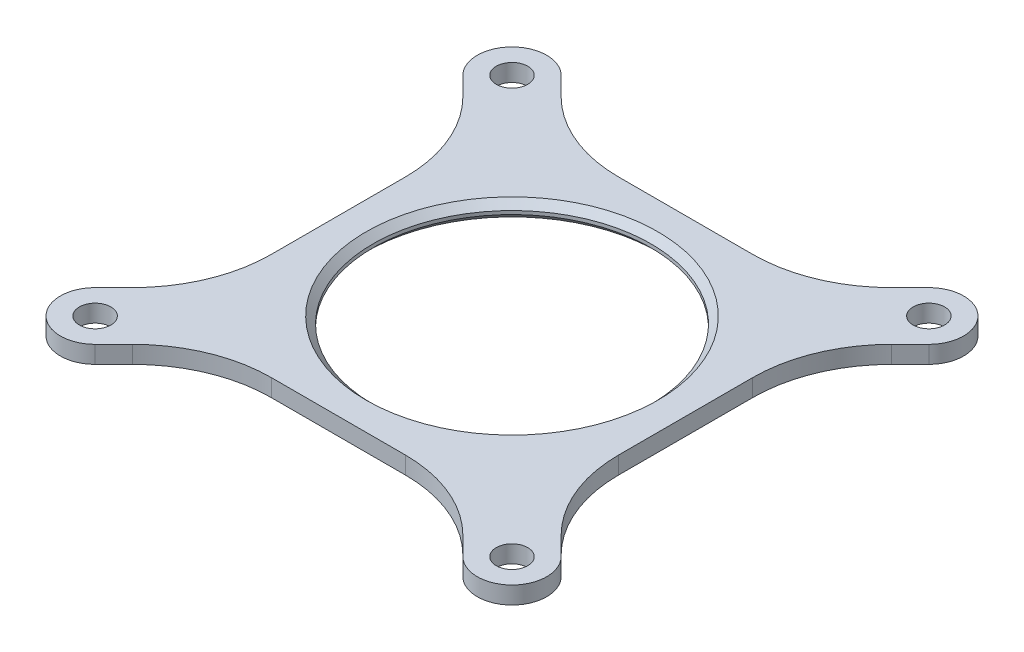
from build123d import *

# Parameters (mm, degrees)
BOSS_EXTRUDE1_DEPTH         = 6.35
SKETCH2_R                   = 50.8
CUT_EXTRUDE1_DEPTH          = 6.35
FILLET1_R                   = 50.8
F_1_2_20_TAPPED_HOLE1_D     = 11.50874
F_1_2_20_TAPPED_HOLE1_DEPTH = 29.21
F_1_2_20_TAPPED_HOLE1_TIP   = 3.45757432
CHAMFER1_SIZE               = 2.54


with BuildPart() as part:
    # Sketch1 → Boss-Extrude1 (new body)
    with BuildSketch(Plane(origin=(0, 0, 0), x_dir=(1, 0, 0), z_dir=(0, 1, 0))):
        with BuildLine():
            Line((-45.539487758, 63.5), (45.539487758, 63.5))
            Line((45.539487758, 63.5), (67.219743879, 85.180256121))
            ThreePointArc((67.219743879, 85.180256121), (85.180256121, 85.180256121), (85.180256121, 67.219743879))
            Line((85.180256121, 67.219743879), (63.5, 45.539487758))
            Line((63.5, 45.539487758), (63.5, -45.539487758))
            Line((63.5, -45.539487758), (85.180256121, -67.219743879))
            ThreePointArc((85.180256121, -67.219743879), (85.180256121, -85.180256121), (67.219743879, -85.180256121))
            Line((67.219743879, -85.180256121), (45.539487758, -63.5))
            Line((45.539487758, -63.5), (-45.539487758, -63.5))
            Line((-45.539487758, -63.5), (-67.219743879, -85.180256121))
            ThreePointArc((-67.219743879, -85.180256121), (-85.180256121, -85.180256121), (-85.180256121, -67.219743879))
            Line((-85.180256121, -67.219743879), (-63.5, -45.539487758))
            Line((-63.5, -45.539487758), (-63.5, 45.539487758))
            Line((-63.5, 45.539487758), (-85.180256121, 67.219743879))
            ThreePointArc((-85.180256121, 67.219743879), (-85.180256121, 85.180256121), (-67.219743879, 85.180256121))
            Line((-67.219743879, 85.180256121), (-45.539487758, 63.5))
        make_face()
    extrude(amount=BOSS_EXTRUDE1_DEPTH)

    # Sketch2 → Cut-Extrude1 (cut)
    with BuildSketch(Plane(origin=(0, 6.35, 0), x_dir=(1, 0, 0), z_dir=(0, 1, 0))):
        Circle(SKETCH2_R)
    extrude(amount=-CUT_EXTRUDE1_DEPTH, mode=Mode.SUBTRACT)

    # Fillet1
    fillet1_edges = [part.edges().sort_by_distance(p)[0] for p in [
        (-63.5, 3.175, 45.539487758),
        (-63.5, 3.175, -45.539487758),
        (-45.539487758, 3.175, -63.5),
        (45.539487758, 3.175, -63.5),
        (63.5, 3.175, -45.539487758),
        (63.5, 3.175, 45.539487758),
        (45.539487758, 3.175, 63.5),
        (-45.539487758, 3.175, 63.5),
    ]]
    fillet(fillet1_edges, radius=FILLET1_R)

    # 1/2-20 Tapped Hole1
    with Locations(Plane(origin=(-76.2, 6.35, -76.2), x_dir=(0, 0, 1), z_dir=(0, 1, 0))):
        with Locations((0, 0), (0, 152.4), (152.4, 152.4), (152.4, 0)):
            Hole(F_1_2_20_TAPPED_HOLE1_D / 2, depth=F_1_2_20_TAPPED_HOLE1_DEPTH)
            with Locations((0, 0, -(F_1_2_20_TAPPED_HOLE1_DEPTH + F_1_2_20_TAPPED_HOLE1_TIP / 2))):  # 118° drill point
                Cone(0, F_1_2_20_TAPPED_HOLE1_D / 2, F_1_2_20_TAPPED_HOLE1_TIP, mode=Mode.SUBTRACT)

    # Chamfer1
    chamfer1_edges = [part.edges().sort_by_distance(p)[0] for p in [
        (-50.8, 0, 0),
        (-50.8, 6.35, 0),
    ]]
    chamfer(chamfer1_edges, length=CHAMFER1_SIZE)


solid = part.part
